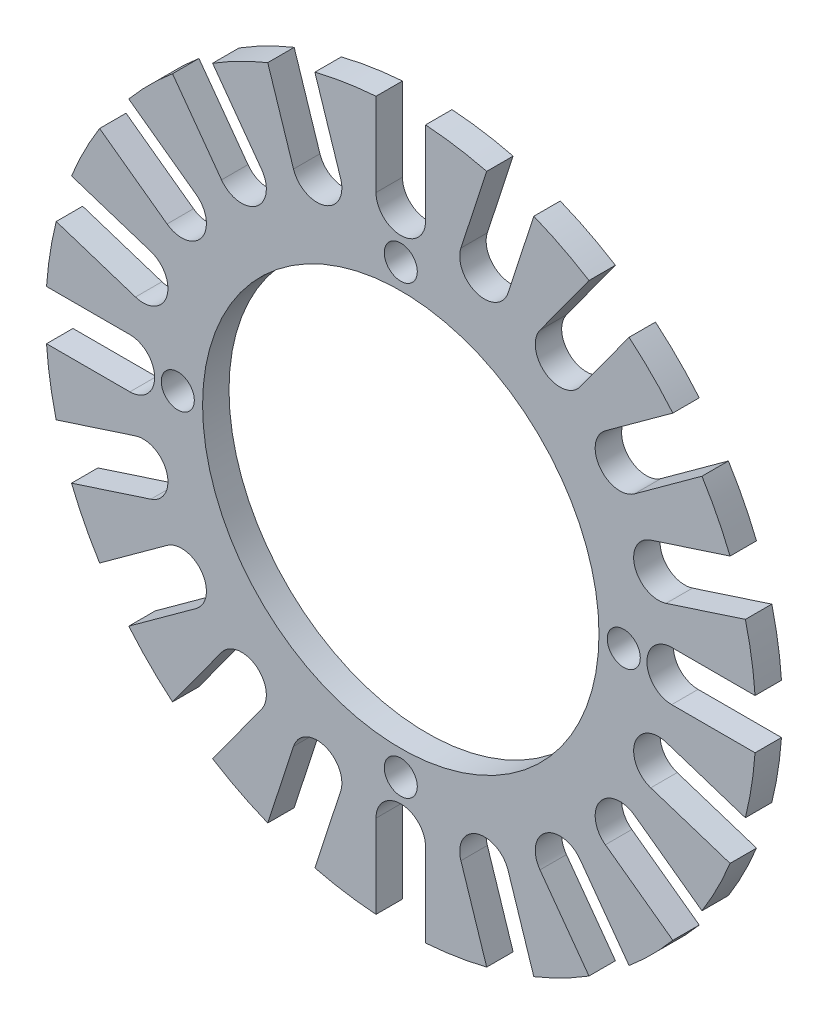
from build123d import *

# Parameters (mm, degrees)
SKETCH1_R           = 12
SKETCH1_R_2         = 1
BOSS_EXTRUDE1_DEPTH = 1.6


with BuildPart() as part:
    # Sketch1 → Boss-Extrude1 (new body)
    with BuildSketch(Plane.XY):
        with BuildLine():
            Line((-1.5, 16.4), (-1.5, 21.44761059))
            ThreePointArc((-1.5, 21.44761059), (-3.363340998, 21.235299323), (-5.201091386, 20.861415302))
            Line((-5.201091386, 20.861415302), (-3.641293933, 16.060852359))
            ThreePointArc((-3.641293933, 16.060852359), (-4.604353216, 14.170742093), (-6.494463482, 15.133801376))
            Line((-6.494463482, 15.133801376), (-8.054260935, 19.934364319))
            ThreePointArc((-8.054260935, 19.934364319), (-9.760795744, 19.15664027), (-11.39306371, 18.233159334))
            Line((-11.39306371, 18.233159334), (-8.426152646, 14.149556586))
            ThreePointArc((-8.426152646, 14.149556586), (-8.758000259, 12.054353216), (-10.853203629, 12.386200829))
            Line((-10.853203629, 12.386200829), (-13.820114693, 16.469803577))
            ThreePointArc((-13.820114693, 16.469803577), (-15.202795796, 15.202795796), (-16.469803577, 13.820114693))
            Line((-16.469803577, 13.820114693), (-12.386200829, 10.853203629))
            ThreePointArc((-12.386200829, 10.853203629), (-12.054353216, 8.758000259), (-14.149556586, 8.426152646))
            Line((-14.149556586, 8.426152646), (-18.233159334, 11.39306371))
            ThreePointArc((-18.233159334, 11.39306371), (-19.15664027, 9.760795744), (-19.934364319, 8.054260935))
            Line((-19.934364319, 8.054260935), (-15.133801376, 6.494463482))
            ThreePointArc((-15.133801376, 6.494463482), (-14.170742093, 4.604353216), (-16.060852359, 3.641293933))
            Line((-16.060852359, 3.641293933), (-20.861415302, 5.201091386))
            ThreePointArc((-20.861415302, 5.201091386), (-21.235299323, 3.363340998), (-21.44761059, 1.5))
            Line((-21.44761059, 1.5), (-16.4, 1.5))
            ThreePointArc((-16.4, 1.5), (-14.9, 0), (-16.4, -1.5))
            Line((-16.4, -1.5), (-21.44761059, -1.5))
            ThreePointArc((-21.44761059, -1.5), (-21.235299323, -3.363340998), (-20.861415302, -5.201091386))
            Line((-20.861415302, -5.201091386), (-16.060852359, -3.641293933))
            ThreePointArc((-16.060852359, -3.641293933), (-14.170742093, -4.604353216), (-15.133801376, -6.494463482))
            Line((-15.133801376, -6.494463482), (-19.934364319, -8.054260935))
            ThreePointArc((-19.934364319, -8.054260935), (-19.15664027, -9.760795744), (-18.233159334, -11.39306371))
            Line((-18.233159334, -11.39306371), (-14.149556586, -8.426152646))
            ThreePointArc((-14.149556586, -8.426152646), (-12.054353216, -8.758000259), (-12.386200829, -10.853203629))
            Line((-12.386200829, -10.853203629), (-16.469803577, -13.820114693))
            ThreePointArc((-16.469803577, -13.820114693), (-15.202795796, -15.202795796), (-13.820114693, -16.469803577))
            Line((-13.820114693, -16.469803577), (-10.853203629, -12.386200829))
            ThreePointArc((-10.853203629, -12.386200829), (-8.758000259, -12.054353216), (-8.426152646, -14.149556586))
            Line((-8.426152646, -14.149556586), (-11.39306371, -18.233159334))
            ThreePointArc((-11.39306371, -18.233159334), (-9.760795744, -19.15664027), (-8.054260935, -19.934364319))
            Line((-8.054260935, -19.934364319), (-6.494463482, -15.133801376))
            ThreePointArc((-6.494463482, -15.133801376), (-4.604353216, -14.170742093), (-3.641293933, -16.060852359))
            Line((-3.641293933, -16.060852359), (-5.201091386, -20.861415302))
            ThreePointArc((-5.201091386, -20.861415302), (-3.363340998, -21.235299323), (-1.5, -21.44761059))
            Line((-1.5, -21.44761059), (-1.5, -16.4))
            ThreePointArc((-1.5, -16.4), (0, -14.9), (1.5, -16.4))
            Line((1.5, -16.4), (1.5, -21.44761059))
            ThreePointArc((1.5, -21.44761059), (3.363340998, -21.235299323), (5.201091386, -20.861415302))
            Line((5.201091386, -20.861415302), (3.641293933, -16.060852359))
            ThreePointArc((3.641293933, -16.060852359), (4.604353216, -14.170742093), (6.494463482, -15.133801376))
            Line((6.494463482, -15.133801376), (8.054260935, -19.934364319))
            ThreePointArc((8.054260935, -19.934364319), (9.760795744, -19.15664027), (11.39306371, -18.233159334))
            Line((11.39306371, -18.233159334), (8.426152646, -14.149556586))
            ThreePointArc((8.426152646, -14.149556586), (8.758000259, -12.054353216), (10.853203629, -12.386200829))
            Line((10.853203629, -12.386200829), (13.820114693, -16.469803577))
            ThreePointArc((13.820114693, -16.469803577), (15.202795796, -15.202795796), (16.469803577, -13.820114693))
            Line((16.469803577, -13.820114693), (12.386200829, -10.853203629))
            ThreePointArc((12.386200829, -10.853203629), (12.054353216, -8.758000259), (14.149556586, -8.426152646))
            Line((14.149556586, -8.426152646), (18.233159334, -11.39306371))
            ThreePointArc((18.233159334, -11.39306371), (19.15664027, -9.760795744), (19.934364319, -8.054260935))
            Line((19.934364319, -8.054260935), (15.133801376, -6.494463482))
            ThreePointArc((15.133801376, -6.494463482), (14.170742093, -4.604353216), (16.060852359, -3.641293933))
            Line((16.060852359, -3.641293933), (20.861415302, -5.201091386))
            ThreePointArc((20.861415302, -5.201091386), (21.235299323, -3.363340998), (21.44761059, -1.5))
            Line((21.44761059, -1.5), (16.4, -1.5))
            ThreePointArc((16.4, -1.5), (14.9, 0), (16.4, 1.5))
            Line((16.4, 1.5), (21.44761059, 1.5))
            ThreePointArc((21.44761059, 1.5), (21.235299323, 3.363340998), (20.861415302, 5.201091386))
            Line((20.861415302, 5.201091386), (16.060852359, 3.641293933))
            ThreePointArc((16.060852359, 3.641293933), (14.170742093, 4.604353216), (15.133801376, 6.494463482))
            Line((15.133801376, 6.494463482), (19.934364319, 8.054260935))
            ThreePointArc((19.934364319, 8.054260935), (19.15664027, 9.760795744), (18.233159334, 11.39306371))
            Line((18.233159334, 11.39306371), (14.149556586, 8.426152646))
            ThreePointArc((14.149556586, 8.426152646), (12.054353216, 8.758000259), (12.386200829, 10.853203629))
            Line((12.386200829, 10.853203629), (16.469803577, 13.820114693))
            ThreePointArc((16.469803577, 13.820114693), (15.202795796, 15.202795796), (13.820114693, 16.469803577))
            Line((13.820114693, 16.469803577), (10.853203629, 12.386200829))
            ThreePointArc((10.853203629, 12.386200829), (8.758000259, 12.054353216), (8.426152646, 14.149556586))
            Line((8.426152646, 14.149556586), (11.39306371, 18.233159334))
            ThreePointArc((11.39306371, 18.233159334), (9.760795744, 19.15664027), (8.054260935, 19.934364319))
            Line((8.054260935, 19.934364319), (6.494463482, 15.133801376))
            ThreePointArc((6.494463482, 15.133801376), (4.604353216, 14.170742093), (3.641293933, 16.060852359))
            Line((3.641293933, 16.060852359), (5.201091386, 20.861415302))
            ThreePointArc((5.201091386, 20.861415302), (3.363340998, 21.235299323), (1.5, 21.44761059))
            Line((1.5, 21.44761059), (1.5, 16.4))
            ThreePointArc((1.5, 16.4), (0, 14.9), (-1.5, 16.4))
        make_face()
        Circle(SKETCH1_R, mode=Mode.SUBTRACT)
        with Locations((0, 13.5)):
            Circle(SKETCH1_R_2, mode=Mode.SUBTRACT)
        with Locations((13.5, 0)):
            Circle(SKETCH1_R_2, mode=Mode.SUBTRACT)
        with Locations((0, -13.5)):
            Circle(SKETCH1_R_2, mode=Mode.SUBTRACT)
        with Locations((-13.5, 0)):
            Circle(SKETCH1_R_2, mode=Mode.SUBTRACT)
    extrude(amount=BOSS_EXTRUDE1_DEPTH)


solid = part.part
